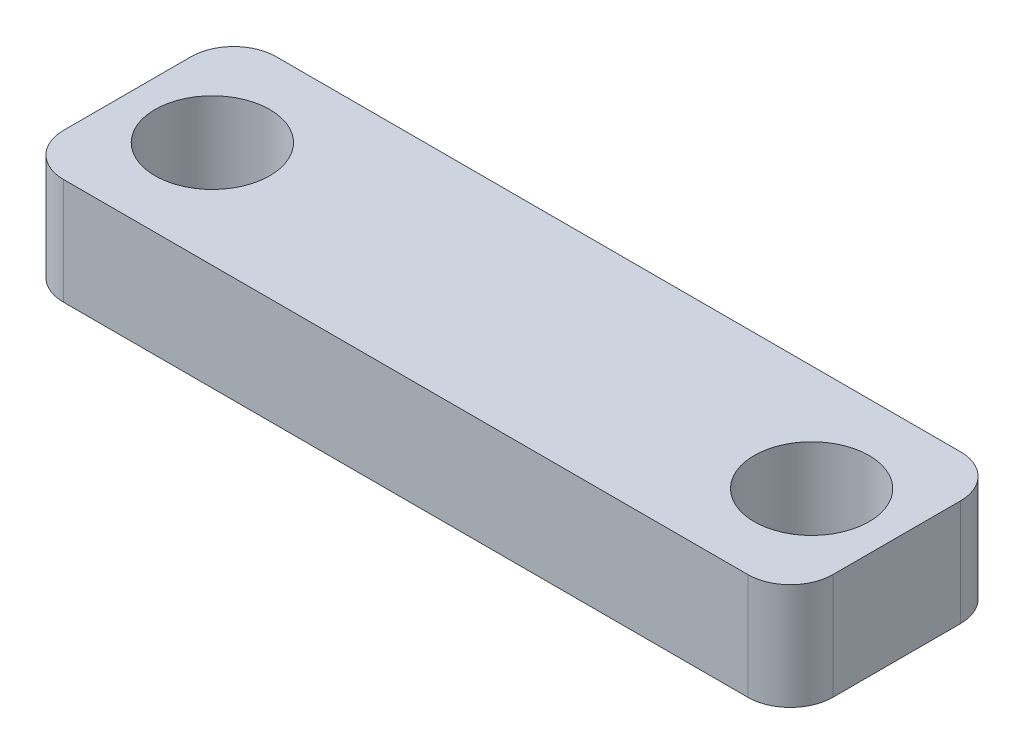
from build123d import *

# Parameters (mm, degrees)
SKETCH1_W              = 18.09
SKETCH1_H              = 5
BOSS_EXTRUDE1_DEPTH    = 2.5
M2_5_CLEARANCE_HOLE1_D = 2.7
FILLET1_R              = 1


with BuildPart() as part:
    # Sketch1 → Boss-Extrude1 (new body)
    with BuildSketch(Plane(origin=(0, 0, 0), x_dir=(1, 0, 0), z_dir=(0, 1, 0))):
        Rectangle(SKETCH1_W, SKETCH1_H)
    extrude(amount=BOSS_EXTRUDE1_DEPTH)

    # M2.5 Clearance Hole1 (through all)
    with Locations(Plane(origin=(0, 0, 0), x_dir=(-1, 0, 0), z_dir=(0, -1, 0))):
        with Locations((-7.045, 0), (7.045, 0)):
            Hole(M2_5_CLEARANCE_HOLE1_D / 2)

    # Fillet1
    fillet1_edges = [part.edges().sort_by_distance(p)[0] for p in [
        (9.045, 1.25, 2.5),
        (-9.045, 1.25, 2.5),
        (-9.045, 1.25, -2.5),
        (9.045, 1.25, -2.5),
    ]]
    fillet(fillet1_edges, radius=FILLET1_R)


solid = part.part
